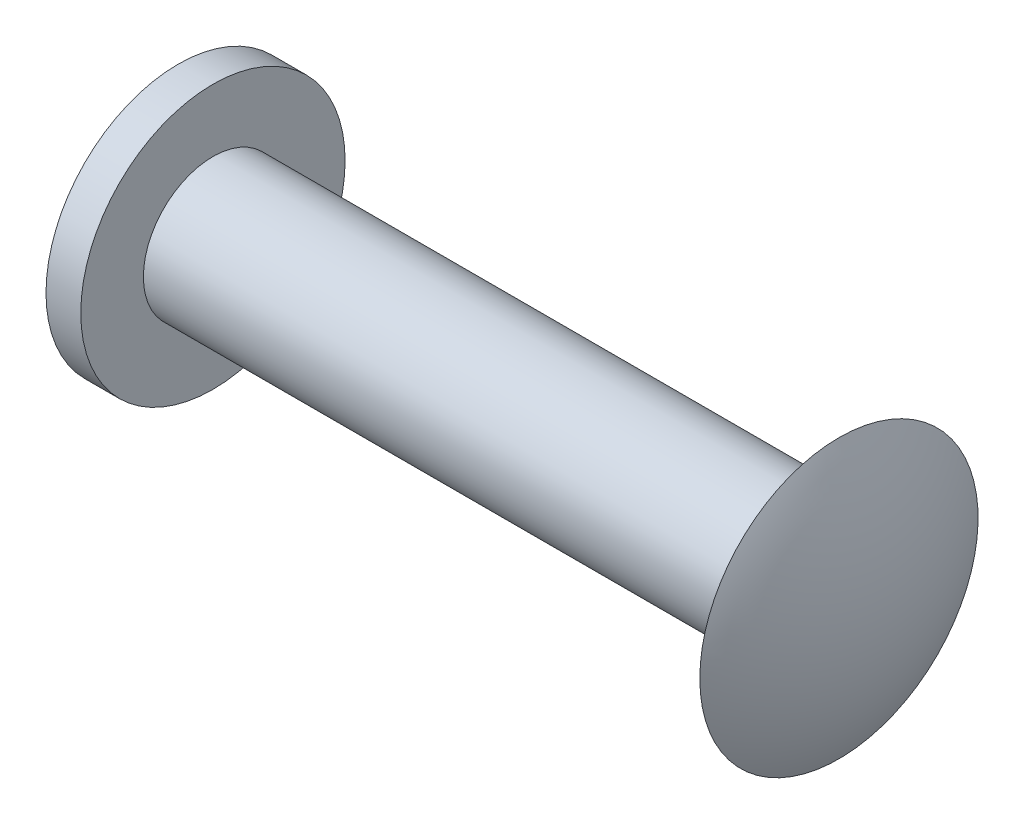
from build123d import *


with BuildPart() as part:
    # Szkic1 → Obrót1 (revolve)
    with BuildSketch(Plane.XY):
        with BuildLine():
            Line((0, 0), (9.5, 0))
            Line((9.5, 0), (10, 0))
            ThreePointArc((10, 0), (9.873105626, 1.030776406), (9.5, 2))
            Line((9.5, 2), (9.5, 1))
            Line((9.5, 1), (0.5, 1))
            Line((0.5, 1), (0.5, 1.9))
            Line((0.5, 1.9), (0, 1.9))
            Line((0, 1.9), (0, 0))
        make_face()
    revolve(axis=Axis((9.5, 0, 0), (1, 0, 0)))


solid = part.part
